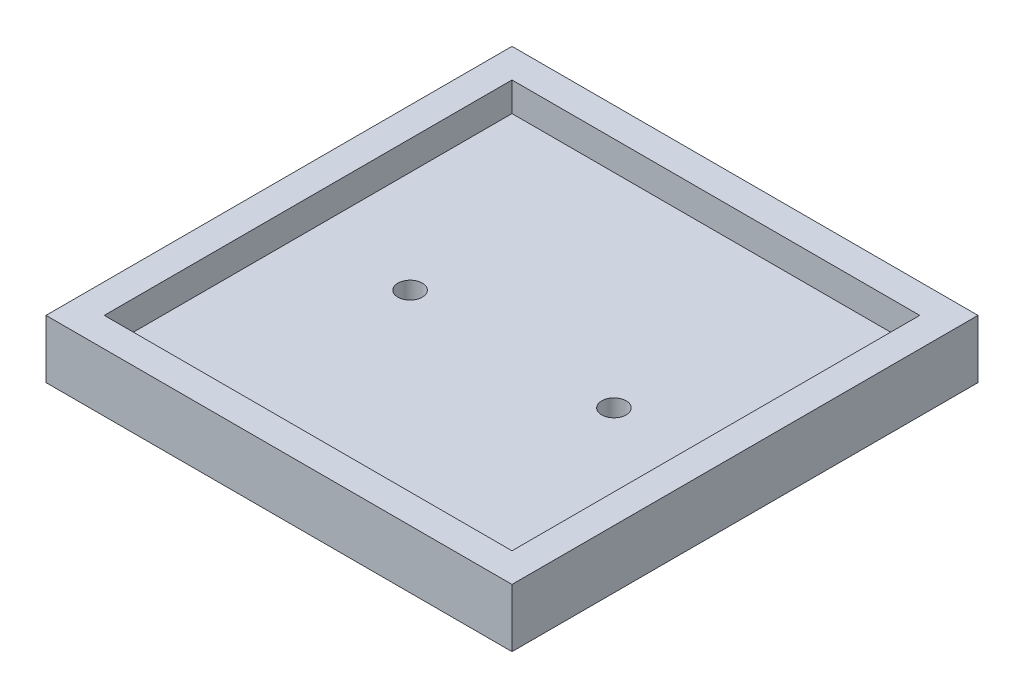
from build123d import *

# Parameters (mm, degrees)
SKETCH1_W           = 80
SKETCH1_H           = 80
BOSS_EXTRUDE1_DEPTH = 5
SKETCH2_W           = 80
SKETCH2_H           = 80
SKETCH2_W_2         = 70
SKETCH2_H_2         = 70
BOSS_EXTRUDE2_DEPTH = 5
CUT_EXTRUDE1_REACH  = 7
SKETCH3_R           = 2.1


with BuildPart() as part:
    # Sketch1 → Boss-Extrude1 (new body)
    with BuildSketch(Plane(origin=(0, 0, 0), x_dir=(1, 0, 0), z_dir=(0, 1, 0))):
        with Locations((40, -40)):
            Rectangle(SKETCH1_W, SKETCH1_H)
    extrude(amount=BOSS_EXTRUDE1_DEPTH)

    # Sketch2 → Boss-Extrude2 (add)
    with BuildSketch(Plane(origin=(0, 5, 0), x_dir=(1, 0, 0), z_dir=(0, 1, 0))):
        with Locations((40, -40)):
            Rectangle(SKETCH2_W, SKETCH2_H)
        with Locations((40, -40)):
            Rectangle(SKETCH2_W_2, SKETCH2_H_2, mode=Mode.SUBTRACT)
    extrude(amount=BOSS_EXTRUDE2_DEPTH)

    # Sketch3 → Cut-Extrude1 (cut, up to next)
    with BuildSketch(Plane(origin=(0, 5, 0), x_dir=(1, 0, 0), z_dir=(0, 1, 0)), mode=Mode.PRIVATE) as cut_extrude1_sk1:
        with Locations((22.5, -40)):
            Circle(SKETCH3_R)
    cut_extrude1_tool1 = extrude(cut_extrude1_sk1.sketch, amount=-CUT_EXTRUDE1_REACH, mode=Mode.PRIVATE) & part.part
    add(cut_extrude1_tool1.solids().sort_by_distance((22.5, 5, 40))[0], mode=Mode.SUBTRACT)
    # Sketch3 → Cut-Extrude1 (cut, up to next)
    with BuildSketch(Plane(origin=(0, 5, 0), x_dir=(1, 0, 0), z_dir=(0, 1, 0)), mode=Mode.PRIVATE) as cut_extrude1_sk2:
        with Locations((57.5, -40)):
            Circle(SKETCH3_R)
    cut_extrude1_tool2 = extrude(cut_extrude1_sk2.sketch, amount=-CUT_EXTRUDE1_REACH, mode=Mode.PRIVATE) & part.part
    add(cut_extrude1_tool2.solids().sort_by_distance((57.5, 5, 40))[0], mode=Mode.SUBTRACT)


solid = part.part
